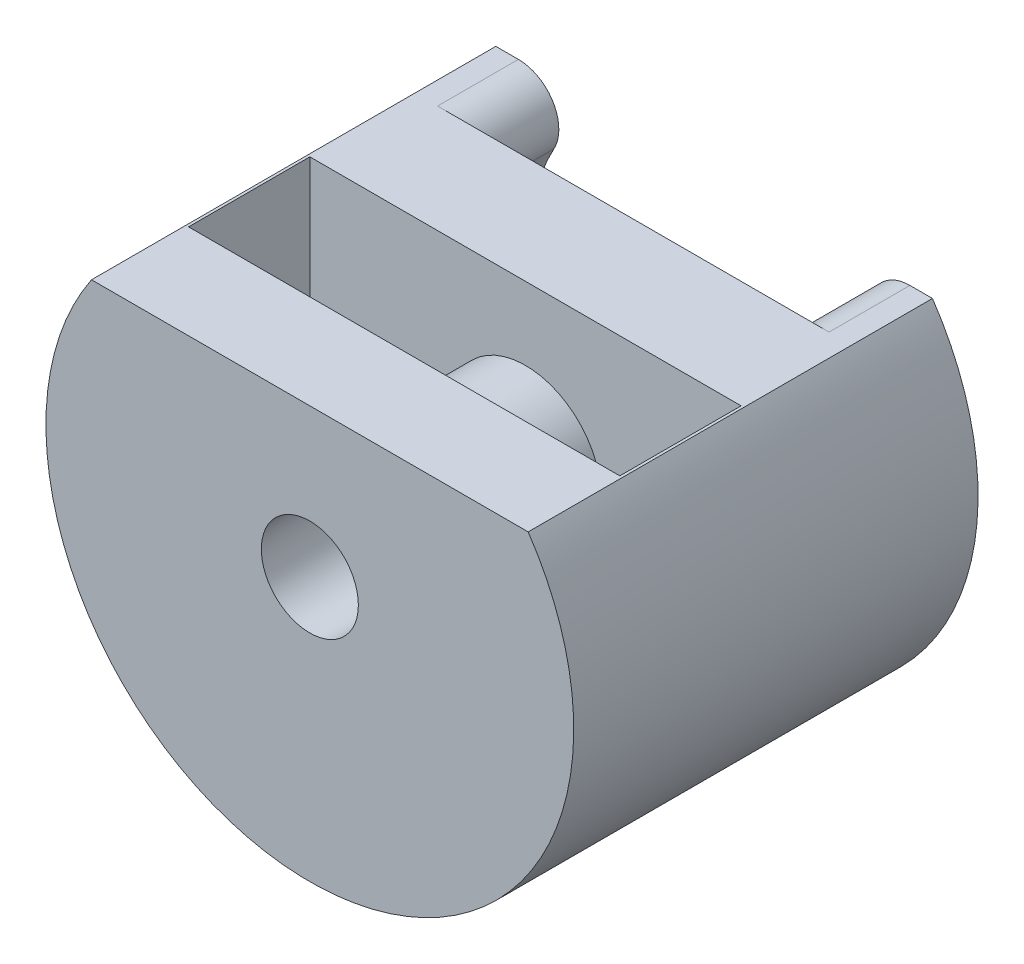
from build123d import *
from build123d.topology import SkipClean

# Parameters (mm, degrees)
BOSS_EXTRUDE1_DEPTH     = 12
SKETCH3_R               = 1.8
CUT_EXTRUDE2_DEPTH      = 13
CUT_EXTRUDE2_DEPTH_BACK = 1
BOSS_EXTRUDE2_DEPTH     = 3
CUT_EXTRUDE4_DEPTH      = 16
SKETCH7_R               = 2.8
SKETCH7_R_2             = 1.8
BOSS_EXTRUDE3_DEPTH     = 8


with BuildPart() as part:
    # Sketch1 → Boss-Extrude1 (new body)
    with BuildSketch(Plane.XY):
        with BuildLine():
            Line((0, 12.5), (16.2, 12.5))
            ThreePointArc((16.2, 12.5), (8.1, -2.790812019), (0, 12.5))
        make_face()
    extrude(amount=BOSS_EXTRUDE1_DEPTH)

    # Sketch3 → Cut-Extrude2 (cut, two sides)
    with BuildSketch(Plane.XY) as cut_extrude2_sk:
        with Locations((8.1, 7)):
            Circle(SKETCH3_R)
    extrude(amount=CUT_EXTRUDE2_DEPTH, mode=Mode.SUBTRACT)
    extrude(cut_extrude2_sk.sketch, amount=-CUT_EXTRUDE2_DEPTH_BACK, mode=Mode.SUBTRACT)

    # Sketch4 → Boss-Extrude2 (add)
    with SkipClean():  # the faces are left unmerged after this step: merging them gives an invalid solid
        with BuildSketch(Plane.XY):
            with BuildLine():
                Line((16.2, 12.5), (15.362063339, 12.5))
                ThreePointArc((15.362063339, 12.5), (14.070641831, 11.763040292), (14.048187812, 10.276307316))
                ThreePointArc((14.048187812, 10.276307316), (8.1, 0.209187981), (2.151812188, 10.276307316))
                ThreePointArc((2.151812188, 10.276307316), (2.129358169, 11.763040292), (0.837936661, 12.5))
                Line((0.837936661, 12.5), (0, 12.5))
                ThreePointArc((0, 12.5), (8.1, -2.790812019), (16.2, 12.5))
            make_face()
        extrude(amount=-BOSS_EXTRUDE2_DEPTH)

    # Sketch6 → Cut-Extrude4 (cut)
    with SkipClean():  # the faces are left unmerged after this step: merging them gives an invalid solid
        with BuildSketch(Plane(origin=(0.1, 0, 0), x_dir=(0, 0, -1), z_dir=(1, 0, 0))):
            with BuildLine():
                Line((-9, 2.60459399), (-4, 2.60459399))
                Line((-4, 2.60459399), (-4, 12.5))
                Line((-4, 12.5), (-8.5, 12.5))
                Line((-8.5, 12.5), (-8.5, 7.10459399))
                Line((-8.5, 7.10459399), (-9, 7.10459399))
                ThreePointArc((-9, 7.10459399), (-11.25, 4.85459399), (-9, 2.60459399))
            make_face()
        extrude(amount=CUT_EXTRUDE4_DEPTH, mode=Mode.SUBTRACT)

    # Sketch7 → Boss-Extrude3 (add)
    with SkipClean():  # the faces are left unmerged after this step: merging them gives an invalid solid
        with BuildSketch(Plane.XY.offset(4)):
            with Locations(Location((8.1, 7, 0), (0, 0, 177.859218285))):
                Circle(SKETCH7_R)
            with Locations((8.1, 7)):
                Circle(SKETCH7_R_2, mode=Mode.SUBTRACT)
        extrude(amount=BOSS_EXTRUDE3_DEPTH)


solid = part.part
